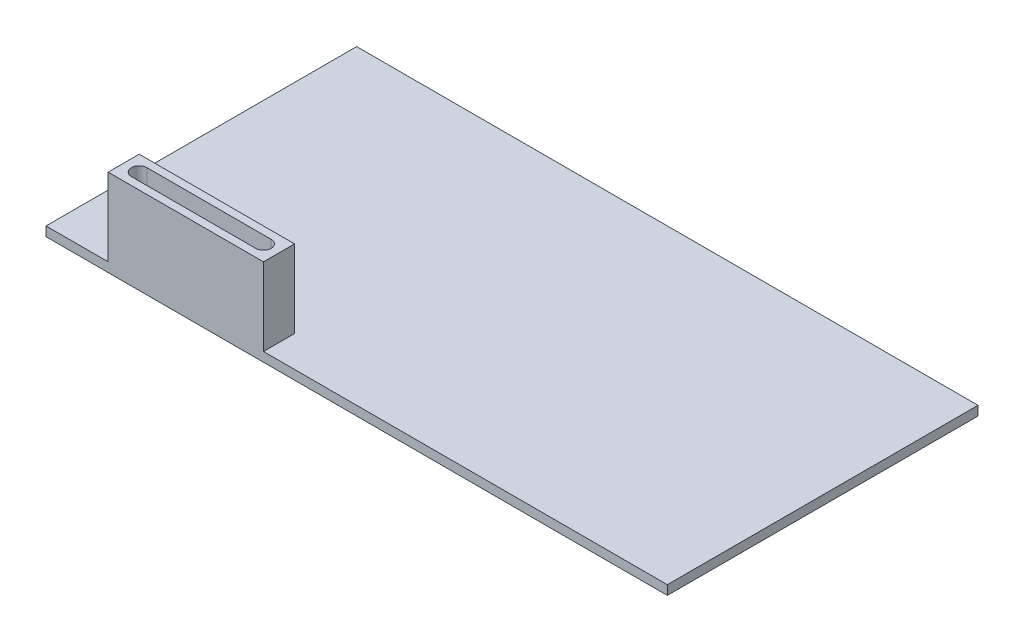
from build123d import *

# Parameters (mm, degrees)
SKETCH1_W           = 200
SKETCH1_H           = 100
BOSS_EXTRUDE1_DEPTH = 3
SKETCH2_W           = 50
SKETCH2_H           = 10
BOSS_EXTRUDE2_DEPTH = 25
CUT_EXTRUDE1_DEPTH  = 29


with BuildPart() as part:
    # Sketch1 → Boss-Extrude1 (new body)
    with BuildSketch(Plane(origin=(0, 0, 0), x_dir=(1, 0, 0), z_dir=(0, 1, 0))):
        Rectangle(SKETCH1_W, SKETCH1_H)
    extrude(amount=BOSS_EXTRUDE1_DEPTH)

    # Sketch2 → Boss-Extrude2 (add)
    with BuildSketch(Plane(origin=(0, 3, 0), x_dir=(1, 0, 0), z_dir=(0, 1, 0))):
        with Locations((-55, -45)):
            Rectangle(SKETCH2_W, SKETCH2_H)
    extrude(amount=BOSS_EXTRUDE2_DEPTH)

    # Sketch3 → Cut-Extrude1 (cut, through all)
    with BuildSketch(Plane(origin=(0, 28, 0), x_dir=(1, 0, 0), z_dir=(0, 1, 0))):
        with BuildLine():
            Line((-75, -42.5), (-35, -42.5))
            ThreePointArc((-35, -42.5), (-32.5, -45), (-35, -47.5))
            Line((-35, -47.5), (-75, -47.5))
            ThreePointArc((-75, -47.5), (-77.5, -45), (-75, -42.5))
        make_face()
    extrude(amount=-CUT_EXTRUDE1_DEPTH, mode=Mode.SUBTRACT)


solid = part.part
